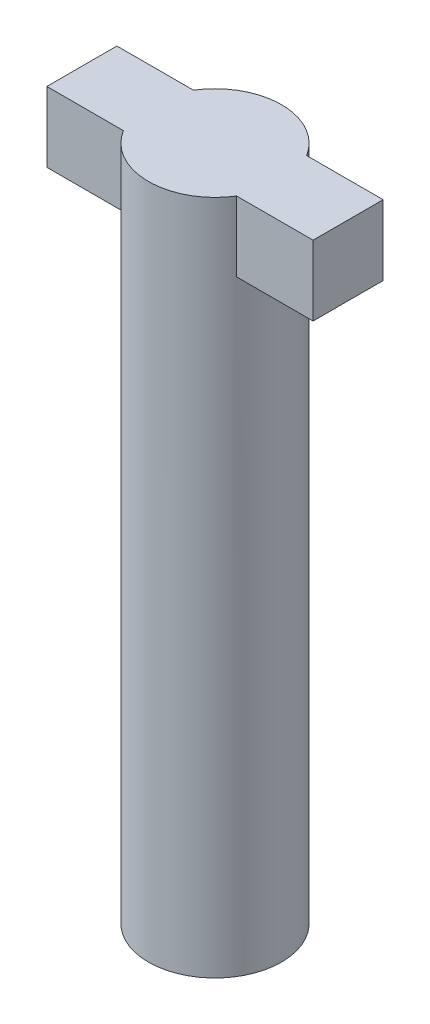
from build123d import *

# Parameters (mm, degrees)
SKETCH1_R  = 0.95
BODY_DEPTH = 9.65
LOCK_DEPTH = 1


with BuildPart() as part:
    # Sketch1 → Body (new body)
    with BuildSketch(Plane(origin=(0, 0, 0), x_dir=(1, 0, 0), z_dir=(0, 1, 0))):
        Circle(SKETCH1_R)
    extrude(amount=BODY_DEPTH)

    # Sketch2 → Lock (add)
    with BuildSketch(Plane(origin=(0, 9.65, 0), x_dir=(1, 0, 0), z_dir=(0, 1, 0))):
        with BuildLine():
            ThreePointArc((-0.807774721, -0.5), (-0.95, 0), (-0.807774721, 0.5))
            Line((-0.807774721, 0.5), (-1.9, 0.5))
            Line((-1.9, 0.5), (-1.9, -0.5))
            Line((-1.9, -0.5), (-0.807774721, -0.5))
        make_face()
        with BuildLine():
            Line((1.9, 0.5), (0.807774721, 0.5))
            ThreePointArc((0.807774721, 0.5), (0.91375215, 0.259917309), (0.95, 0))
            ThreePointArc((0.95, 0), (0.91375215, -0.259917309), (0.807774721, -0.5))
            Line((0.807774721, -0.5), (1.9, -0.5))
            Line((1.9, -0.5), (1.9, 0.5))
        make_face()
    extrude(amount=-LOCK_DEPTH)


solid = part.part
